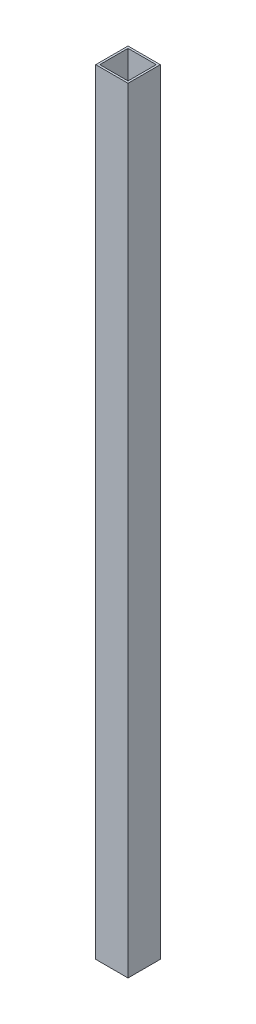
from build123d import *

# Parameters (mm, degrees)
SKETCH1_W           = 25.4
SKETCH1_H           = 25.4
SKETCH1_W_2         = 22.225
SKETCH1_H_2         = 22.225
BOSS_EXTRUDE1_DEPTH = 609.6


with BuildPart() as part:
    # Sketch1 → Boss-Extrude1 (new body)
    with BuildSketch(Plane(origin=(0, 0, 0), x_dir=(1, 0, 0), z_dir=(0, 1, 0))):
        Rectangle(SKETCH1_W, SKETCH1_H)
        Rectangle(SKETCH1_W_2, SKETCH1_H_2, mode=Mode.SUBTRACT)
    extrude(amount=BOSS_EXTRUDE1_DEPTH)


solid = part.part
